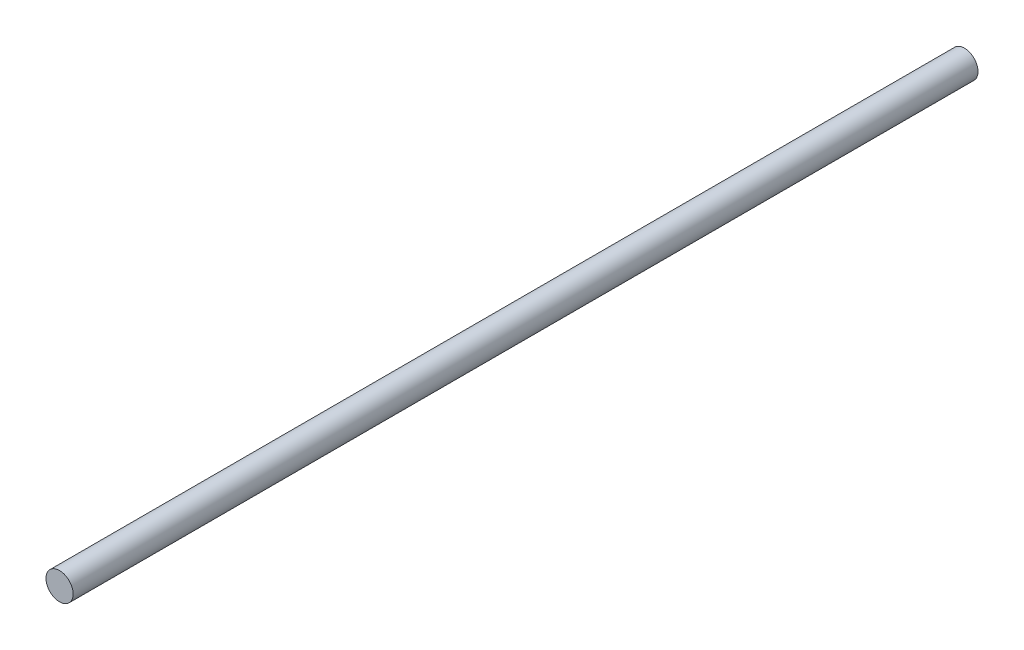
from build123d import *

# Parameters (mm, degrees)
SKETCH1_R           = 3
BOSS_EXTRUDE1_DEPTH = 200


with BuildPart() as part:
    # Sketch1 → Boss-Extrude1 (new body)
    with BuildSketch(Plane.XY):
        Circle(SKETCH1_R)
    extrude(amount=-BOSS_EXTRUDE1_DEPTH)


solid = part.part
